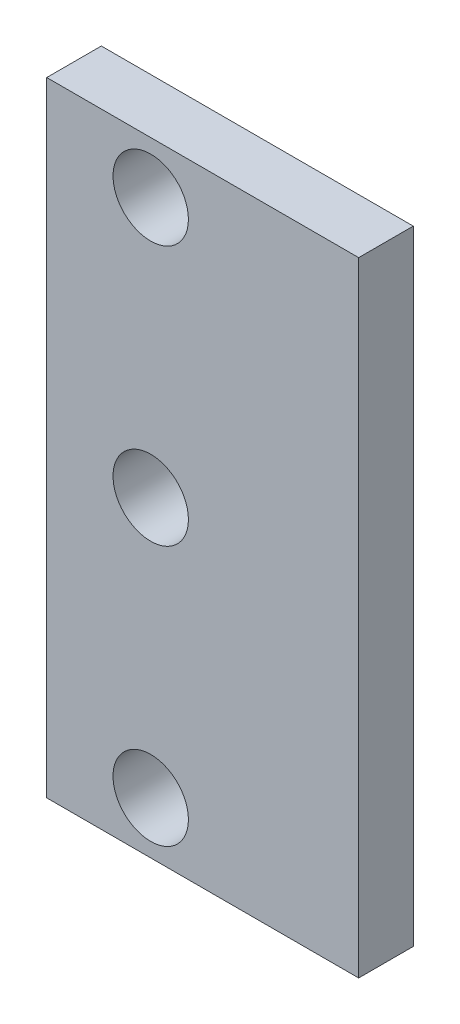
from build123d import *

# Parameters (mm, degrees)
SKETCH_1_W      = 30
SKETCH_1_H      = 60
SKETCH_1_R      = 3.625
EXTRUDE_1_DEPTH = 5.25


with BuildPart() as part:
    # 스케치1 → 보스-돌출1 (new body)
    with BuildSketch(Plane.XY):
        Rectangle(SKETCH_1_W, SKETCH_1_H)
        with Locations((-5, 25)):
            Circle(SKETCH_1_R, mode=Mode.SUBTRACT)
        with Locations((-5, 0)):
            Circle(SKETCH_1_R, mode=Mode.SUBTRACT)
        with Locations((-5, -25)):
            Circle(SKETCH_1_R, mode=Mode.SUBTRACT)
    extrude(amount=EXTRUDE_1_DEPTH)


solid = part.part
